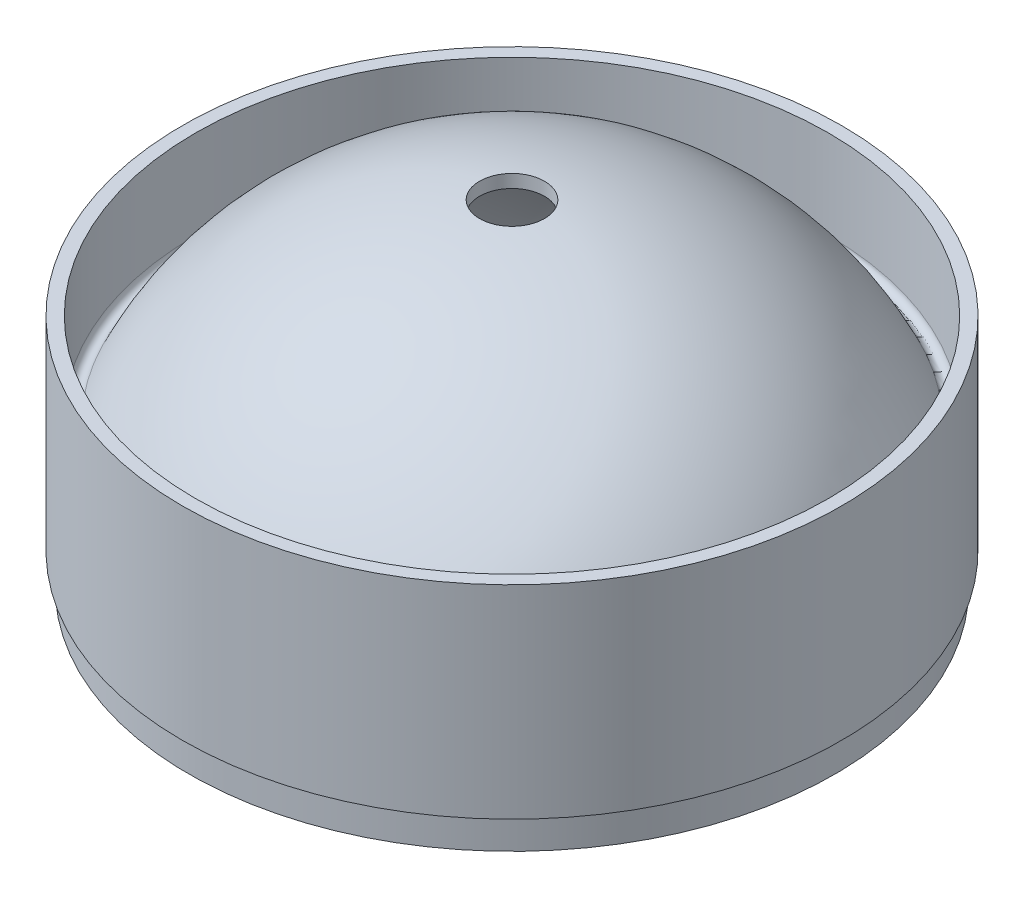
from build123d import *

# Parameters (mm, degrees)
SKETCH3_R          = 12.5
CUT_EXTRUDE1_DEPTH = 1000


with BuildPart() as part:
    # Sketch2 → Revolve1 (revolve)
    with BuildSketch(Plane.XY):
        with BuildLine():
            Line((127, 900), (127, 965.730277379))
            Line((127, 965.730277379), (122, 965.730277379))
            Line((122, 965.730277379), (122, 931.460554757))
            ThreePointArc((122, 931.460554757), (120.042413497, 929.02010652), (117.235369921, 930.401569108))
            ThreePointArc((117.235369921, 930.401569108), (69.478517997, 984.769156682), (0, 1005))
            Line((0, 1005), (0, 1000))
            ThreePointArc((0, 1000), (78.873316147, 971.805445699), (122, 900))
            Line((122, 900), (122, 875))
            Line((122, 875), (124.5, 875))
            Line((124.5, 875), (124.5, 887.5))
            Line((124.5, 887.5), (127, 887.5))
            Line((127, 887.5), (127, 900))
        make_face()
    revolve(axis=Axis((0, 0, 0), (0, 1, 0)))

    # Sketch3 → Cut-Extrude1 (cut)
    with BuildSketch(Plane.XZ.offset(-875)):
        Circle(SKETCH3_R)
    extrude(amount=-CUT_EXTRUDE1_DEPTH, mode=Mode.SUBTRACT)


solid = part.part
